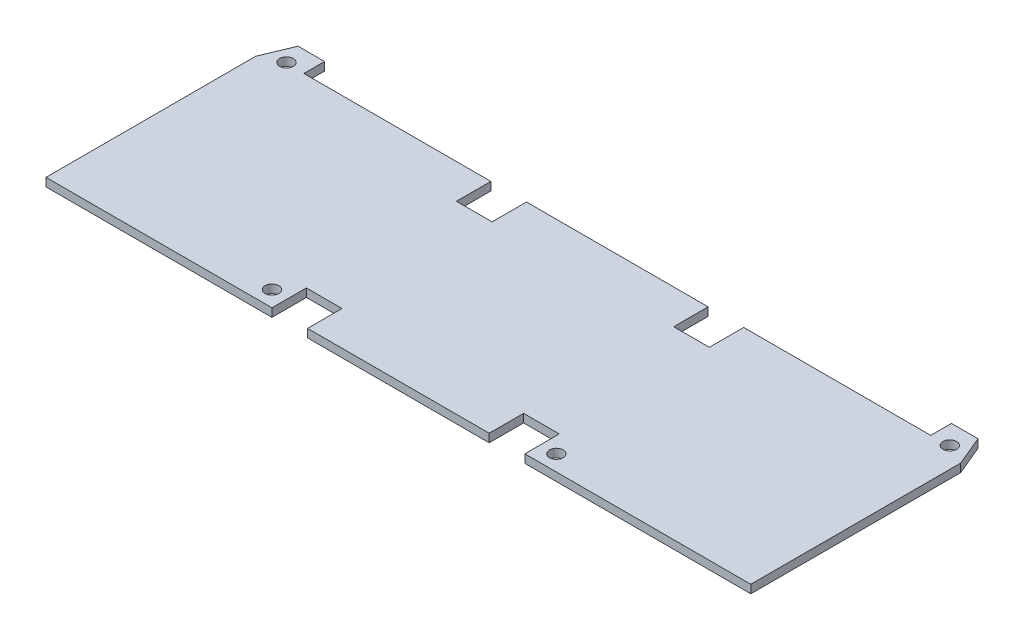
from build123d import *

# Parameters (mm, degrees)
BOSS_EXTRU_1_DEPTH           = 2
ESQUISSE2_R                  = 1.65
ENL_V_MAT_EXTRU_1_DEPTH      = 1
ENL_V_MAT_EXTRU_1_DEPTH_BACK = 3


with BuildPart() as part:
    # Esquisse1 → Boss.-Extru.1 (new body)
    with BuildSketch(Plane(origin=(0, 0, 0), x_dir=(1, 0, 0), z_dir=(0, 1, 0))):
        Polygon((21.9, 26.4), (-21.9, 26.4), (-21.9, 18.1), (-30.5, 18.1), (-30.5, 26.4), (-75.6, 26.4), (-75.6, 31.4), (-82, 31.4), (-85, 24.2), (-85, -26.4), (-30.5, -26.4), (-30.5, -18.1), (-21.9, -18.1), (-21.9, -26.4), (21.9, -26.4), (21.9, -18.1), (30.5, -18.1), (30.5, -26.4), (85, -26.4), (85, 24.2), (82, 31.4), (75.6, 31.4), (75.6, 26.4), (30.5, 26.4), (30.5, 18.1), (21.9, 18.1), align=None)
    extrude(amount=BOSS_EXTRU_1_DEPTH)

    # Esquisse2 → Enlèv. mat.-Extru.1 (cut, two sides)
    with BuildSketch(Plane(origin=(0, 2, 0), x_dir=(1, 0, 0), z_dir=(0, 1, 0))) as enl_v_mat_extru_1_sk:
        with Locations((-80, 26.6)):
            Circle(ESQUISSE2_R)
        with Locations((-34.3, -22.6)):
            Circle(ESQUISSE2_R)
        with Locations((34.3, -22.6)):
            Circle(ESQUISSE2_R)
        with Locations((80, 26.6)):
            Circle(ESQUISSE2_R)
    extrude(amount=ENL_V_MAT_EXTRU_1_DEPTH, mode=Mode.SUBTRACT)
    extrude(enl_v_mat_extru_1_sk.sketch, amount=-ENL_V_MAT_EXTRU_1_DEPTH_BACK, mode=Mode.SUBTRACT)


solid = part.part
